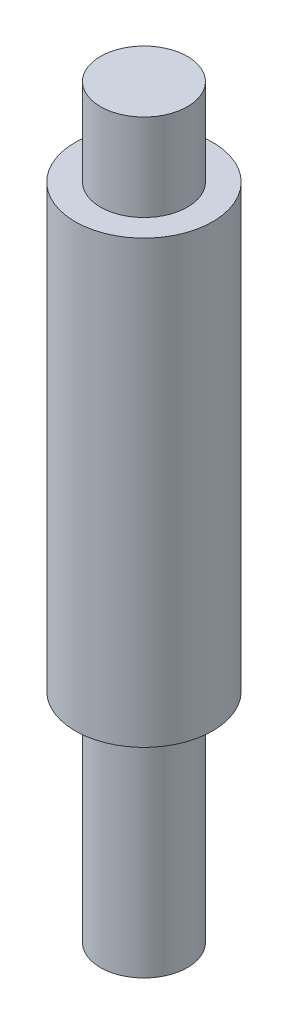
from build123d import *

# Parameters (mm, degrees)
SKETCH1_R                        = 6.35
BUSHINGSPROCKETSPACE_DEPTH       = 31.75
SKETCH2_R                        = 10.033
BOSS_EXTRUDE2_DEPTH              = 64.3509
SKETCH3_R                        = 6.35
BOSS_EXTRUDE3_DEPTH              = 12.7
F_10_24_TAPPED_HOLE2_D           = 3.7973
F_10_24_TAPPED_HOLE2_DEPTH       = 10.16
F_10_24_TAPPED_HOLE2_CSINK_D     = 5.0673
F_10_24_TAPPED_HOLE2_CSINK_ANGLE = 90
F_10_24_TAPPED_HOLE2_TIP         = 1.140824014


with BuildPart() as part:
    # Sketch1 → BushingSprocketSpace (new body)
    with BuildSketch(Plane(origin=(0, 0, 0), x_dir=(1, 0, 0), z_dir=(0, 1, 0))):
        Circle(SKETCH1_R)
    extrude(amount=BUSHINGSPROCKETSPACE_DEPTH)

    # Sketch2 → Boss-Extrude2 (add)
    with BuildSketch(Plane(origin=(0, 31.75, 0), x_dir=(1, 0, 0), z_dir=(0, 1, 0))):
        Circle(SKETCH2_R)
    extrude(amount=BOSS_EXTRUDE2_DEPTH)

    # Sketch3 → Boss-Extrude3 (add)
    with BuildSketch(Plane(origin=(0, 96.1009, 0), x_dir=(1, 0, 0), z_dir=(0, 1, 0))):
        Circle(SKETCH3_R)
    extrude(amount=BOSS_EXTRUDE3_DEPTH)

    # #10-24 Tapped Hole2
    with Locations(Plane(origin=(0, 64.25184, -10.033), x_dir=(-1, 0, 0), z_dir=(0, 0, -1))):
        with Locations((0, 0)):
            CounterSinkHole(F_10_24_TAPPED_HOLE2_D / 2, F_10_24_TAPPED_HOLE2_CSINK_D / 2, depth=F_10_24_TAPPED_HOLE2_DEPTH, counter_sink_angle=F_10_24_TAPPED_HOLE2_CSINK_ANGLE)
            with Locations((0, 0, -(F_10_24_TAPPED_HOLE2_DEPTH + F_10_24_TAPPED_HOLE2_TIP / 2))):  # 118° drill point
                Cone(0, F_10_24_TAPPED_HOLE2_D / 2, F_10_24_TAPPED_HOLE2_TIP, mode=Mode.SUBTRACT)


solid = part.part
